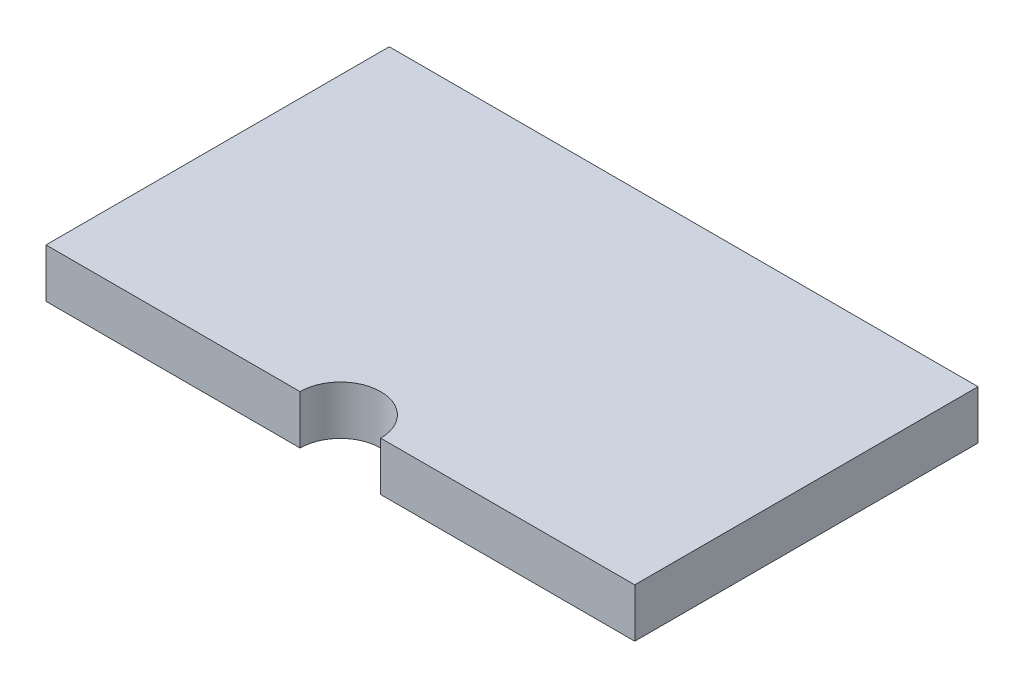
from build123d import *

# Parameters (mm, degrees)
SKETCH1_W           = 61.214
SKETCH1_H           = 35.687
BOSS_EXTRUDE1_DEPTH = 5.08
SKETCH2_R           = 4.191
CUT_EXTRUDE1_DEPTH  = 6.08


with BuildPart() as part:
    # Sketch1 → Boss-Extrude1 (new body)
    with BuildSketch(Plane(origin=(0, 0, 0), x_dir=(1, 0, 0), z_dir=(0, 1, 0))):
        Rectangle(SKETCH1_W, SKETCH1_H)
    extrude(amount=BOSS_EXTRUDE1_DEPTH)

    # Sketch2 → Cut-Extrude1 (cut, through all)
    with BuildSketch(Plane(origin=(0, 5.08, 0), x_dir=(1, 0, 0), z_dir=(0, 1, 0))):
        with Locations((0, -17.8435)):
            Circle(SKETCH2_R)
    extrude(amount=-CUT_EXTRUDE1_DEPTH, mode=Mode.SUBTRACT)


solid = part.part
